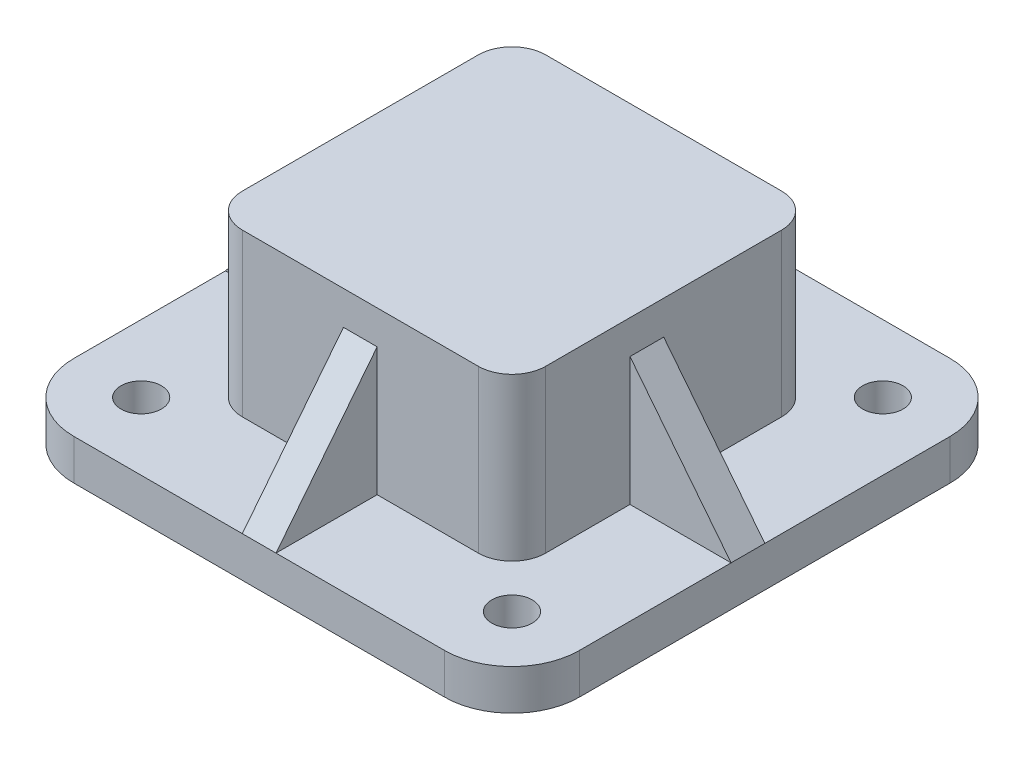
from build123d import *

# Parameters (mm, degrees)
SKETCH1_R           = 6
BOSS_EXTRUDE2_DEPTH = 12
BOSS_EXTRUDE3_DEPTH = 48
BOSS_EXTRUDE5_DEPTH = 5
BOSS_EXTRUDE6_DEPTH = 10


with BuildPart() as part:
    # Sketch1 → Boss-Extrude2 (new body)
    with BuildSketch(Plane(origin=(0, 0, 0), x_dir=(1, 0, 0), z_dir=(0, 1, 0))):
        with BuildLine():
            Line((-55, 75), (55, 75))
            ThreePointArc((55, 75), (69.142135624, 69.142135624), (75, 55))
            Line((75, 55), (75, -55))
            ThreePointArc((75, -55), (69.142135624, -69.142135624), (55, -75))
            Line((55, -75), (-55, -75))
            ThreePointArc((-55, -75), (-69.142135624, -69.142135624), (-75, -55))
            Line((-75, -55), (-75, 55))
            ThreePointArc((-75, 55), (-69.142135624, 69.142135624), (-55, 75))
        make_face()
        with Locations((-55, 55)):
            Circle(SKETCH1_R, mode=Mode.SUBTRACT)
        with Locations((-55, -55)):
            Circle(SKETCH1_R, mode=Mode.SUBTRACT)
        with Locations((55, -55)):
            Circle(SKETCH1_R, mode=Mode.SUBTRACT)
        with Locations((55, 55)):
            Circle(SKETCH1_R, mode=Mode.SUBTRACT)
    extrude(amount=BOSS_EXTRUDE2_DEPTH)

    # Sketch2 → Boss-Extrude3 (add)
    with BuildSketch(Plane(origin=(0, 12, 0), x_dir=(1, 0, 0), z_dir=(0, 1, 0))):
        with BuildLine():
            Line((-35, 45), (35, 45))
            ThreePointArc((35, 45), (42.071067812, 42.071067812), (45, 35))
            Line((45, 35), (45, -35))
            ThreePointArc((45, -35), (42.071067812, -42.071067812), (35, -45))
            Line((35, -45), (-35, -45))
            ThreePointArc((-35, -45), (-42.071067812, -42.071067812), (-45, -35))
            Line((-45, -35), (-45, 35))
            ThreePointArc((-45, 35), (-42.071067812, 42.071067812), (-35, 45))
        make_face()
    extrude(amount=BOSS_EXTRUDE3_DEPTH)

    # Sketch3 → Boss-Extrude5 (add, symmetric)
    with BuildSketch(Plane(origin=(0, 0, 0), x_dir=(0, 0, -1), z_dir=(1, 0, 0))):
        Polygon((45, 50), (45, 12), (75, 12), align=None)
        Polygon((-45, 12), (-75, 12), (-45, 50), align=None)
    extrude(amount=BOSS_EXTRUDE5_DEPTH, both=True)

    # Sketch6 → Boss-Extrude6 (add)
    with BuildSketch(Plane.XY):
        Polygon((45, 50), (75, 12), (45, 12), align=None)
        Polygon((-45, 50), (-45, 12), (-75, 12), align=None)
    extrude(amount=BOSS_EXTRUDE6_DEPTH)


solid = part.part
